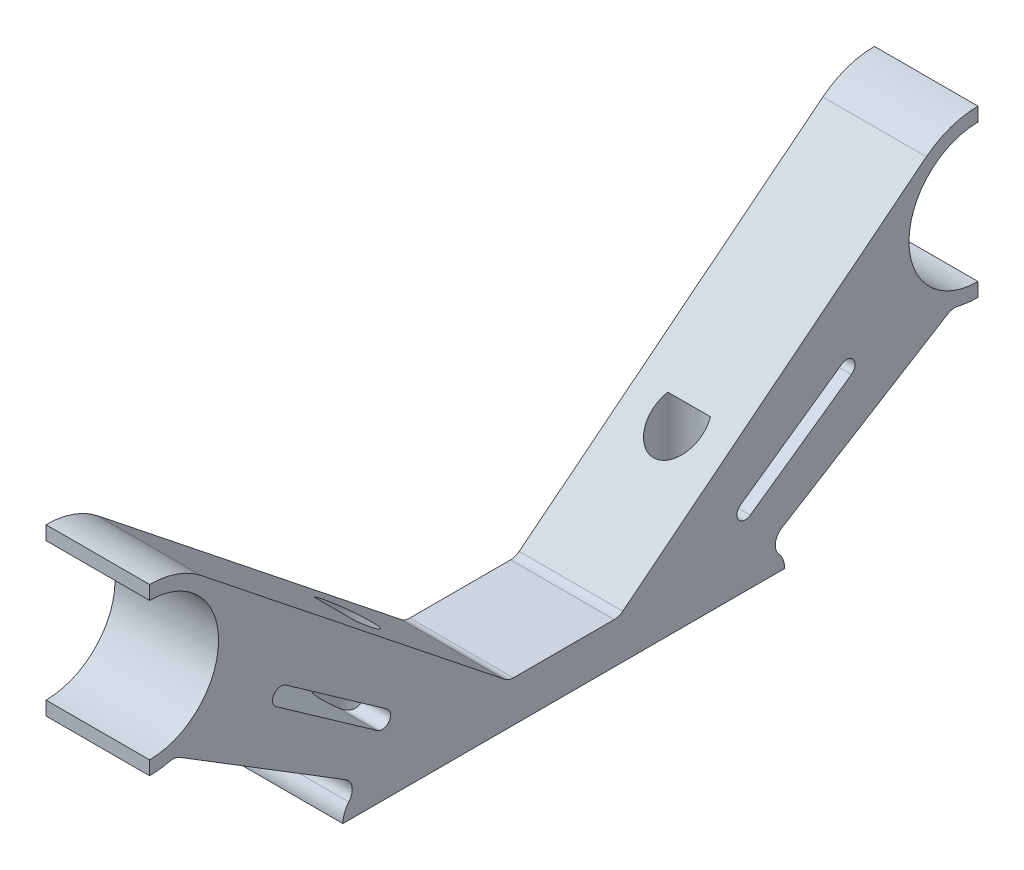
from build123d import *

# Parameters (mm, degrees)
ESTRUSIONE_ESTRUSIONE1_DEPTH = 3.75
RACCORDO2_R                  = 1
SCHIZZO3_R                   = 1.75
TAGLIO_ESTRUSIONE1_DEPTH     = 10


with BuildPart() as part:
    # Schizzo1 → Estrusione-Estrusione1 (new body, symmetric)
    with BuildSketch(Plane(origin=(0, 0, 0), x_dir=(0, 0, -1), z_dir=(1, 0, 0))):
        with BuildLine():
            Line((-30, 22), (-30, 21))
            ThreePointArc((-30, 21), (-25, 16), (-30, 11))
            Line((-30, 11), (-30, 10))
            ThreePointArc((-30, 10), (-29.075946517, 10.07158325), (-28.173941951, 10.284624946))
            Line((-28.173941951, 10.284624946), (-14.279791844, 1.720208156))
            ThreePointArc((-14.279791844, 1.720208156), (-15.496162696, 1.216370852), (-16, 0))
            Line((-16, 0), (16, 0))
            ThreePointArc((16, 0), (15.496162696, 1.216370852), (14.279791844, 1.720208156))
            Line((14.279791844, 1.720208156), (28.173941951, 10.284624946))
            ThreePointArc((28.173941951, 10.284624946), (29.075946517, 10.07158325), (30, 10))
            Line((30, 10), (30, 11))
            ThreePointArc((30, 11), (25, 16), (30, 21))
            Line((30, 21), (30, 22))
            ThreePointArc((30, 22), (28.020680207, 21.664123335), (26.262962858, 20.694097719))
            Line((26.262962858, 20.694097719), (4, 2.970240215))
            Line((4, 2.970240215), (-4, 2.970240215))
            Line((-4, 2.970240215), (-26.262962858, 20.694097719))
            ThreePointArc((-26.262962858, 20.694097719), (-28.020680207, 21.664123335), (-30, 22))
        make_face()
        with BuildLine():
            Line((-20.125796974, 10.754754637), (-12.80100478, 5.593685162))
            ThreePointArc((-12.80100478, 5.593685162), (-12.653117343, 4.740293889), (-13.506508616, 4.592406452))
            Line((-13.506508616, 4.592406452), (-20.83130081, 9.753475926))
            ThreePointArc((-20.83130081, 9.753475926), (-20.979188247, 10.606867199), (-20.125796974, 10.754754637))
        make_face(mode=Mode.SUBTRACT)
        with BuildLine():
            Line((20.125796974, 10.754754637), (12.80100478, 5.593685162))
            ThreePointArc((12.80100478, 5.593685162), (12.653117343, 4.740293889), (13.506508616, 4.592406452))
            Line((13.506508616, 4.592406452), (20.83130081, 9.753475926))
            ThreePointArc((20.83130081, 9.753475926), (20.979188247, 10.606867199), (20.125796974, 10.754754637))
        make_face(mode=Mode.SUBTRACT)
    extrude(amount=ESTRUSIONE_ESTRUSIONE1_DEPTH, both=True)

    # Raccordo2
    raccordo2_edges = [part.edges().sort_by_distance(p)[0] for p in [
        (0, 2.970240215, 4),
        (0, 2.970240215, -4),
        (0, 10.284624946, -28.173941951),
        (0, 1.720208156, -14.279791844),
        (0, 1.720208156, 14.279791844),
        (0, 10.284624946, 28.173941951),
    ]]
    fillet(raccordo2_edges, radius=RACCORDO2_R)

    # Schizzo3 → Taglio-Estrusione1 (cut)
    with BuildSketch(Plane.XZ):
        with Locations((0, 12)):
            Circle(SCHIZZO3_R)
    taglio_estrusione1 = extrude(amount=-TAGLIO_ESTRUSIONE1_DEPTH, mode=Mode.SUBTRACT)

    # Specchia1: Taglio-Estrusione1 across plane
    add(taglio_estrusione1.mirror(Plane.XY), mode=Mode.SUBTRACT)


solid = part.part
